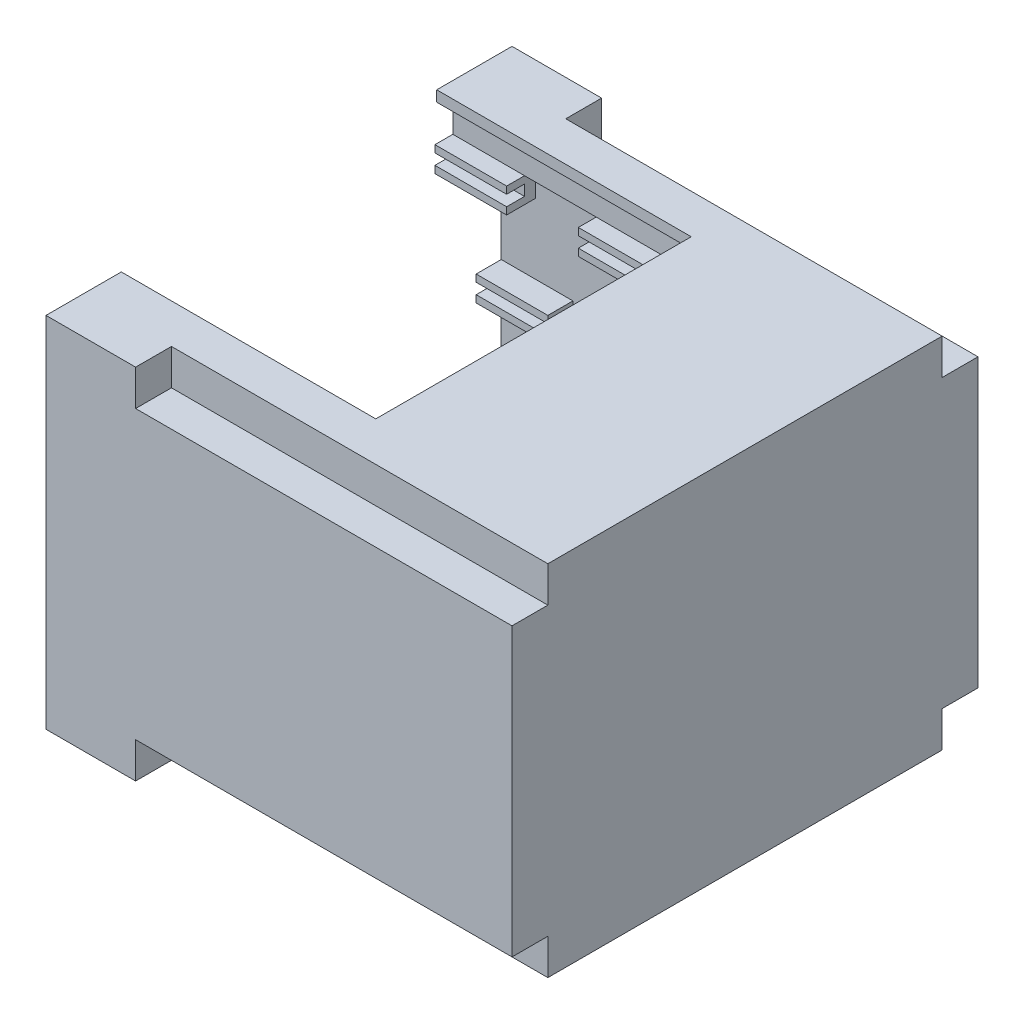
from build123d import *

# Parameters (mm, degrees)
SKETCH2_W                = 130
SKETCH2_H                = 130
BOSS_EXTRUDE1_DEPTH      = 100
SKETCH3_W                = 104
SKETCH3_H                = 74
CUT_EXTRUDE1_DEPTH       = 127
SKETCH4_W                = 10
SKETCH4_H                = 10
CUT_EXTRUDE3_DEPTH       = 105
SKETCH5_W                = 104
SKETCH5_H                = 10
CUT_EXTRUDE4_DEPTH       = 127
SKETCH6_W                = 10
SKETCH6_H                = 74
CUT_EXTRUDE5_DEPTH       = 127
SKETCH7_R                = 1.75
CUT_EXTRUDE6_DEPTH       = 20
SKETCH8_W                = 3
SKETCH8_H                = 3
CUT_EXTRUDE7_DEPTH       = 5
SKETCH9_W                = 85
SKETCH9_H                = 60
BOSS_EXTRUDE2_DEPTH      = 15
SKETCH11_W               = 85
SKETCH11_H               = 6
BOSS_EXTRUDE5_DEPTH      = 5
SKETCH12_W               = 85
SKETCH12_H               = 3
CUT_EXTRUDE9_DEPTH       = 4
SKETCH13_W               = 82
SKETCH13_H               = 57
CUT_EXTRUDE10_DEPTH      = 15
SKETCH15_W               = 3
SKETCH15_H               = 3
BOSS_EXTRUDE7_DEPTH      = 5
SKETCH16_W               = 82
SKETCH16_H               = 2
BOSS_EXTRUDE8_DEPTH      = 57
SKETCH17_W               = 77
SKETCH17_H               = 47
CUT_EXTRUDE11_DEPTH      = 10
SKETCH19_W               = 7
SKETCH19_H               = 2
SKETCH19_H_2             = 1
BOSS_EXTRUDE9_DEPTH      = 1
SKETCH21_W               = 3
SKETCH21_H               = 3
CUT_EXTRUDE15_DEPTH      = 5
SKETCH22_W               = 124
SKETCH22_H               = 7
BOSS_EXTRUDE10_DEPTH     = 127
SKETCH23_W               = 120
SKETCH23_H               = 3
CUT_EXTRUDE16_DEPTH      = 125
SKETCH24_W               = 120
SKETCH24_H               = 110
CUT_EXTRUDE17_DEPTH      = 15
SKETCH25_W               = 71
SKETCH25_H               = 88
CUT_EXTRUDE18_DEPTH      = 15
SKETCH27_W               = 103
SKETCH27_H               = 17
BOSS_EXTRUDE11_DEPTH     = 127
SKETCH28_W               = 97
SKETCH28_H               = 3
SKETCH28_H_2             = 10
CUT_EXTRUDE19_DEPTH      = 120
SKETCH29_W               = 4
SKETCH29_H               = 103
CUT_EXTRUDE20_DEPTH      = 17
SKETCH30_W               = 115
SKETCH30_H               = 87
CUT_EXTRUDE21_DEPTH      = 17
SKETCH31_W               = 20
SKETCH31_H               = 124
CUT_EXTRUDE22_DEPTH      = 37
CUT_EXTRUDE22_DEPTH_BACK = 36
SKETCH32_R               = 3
CUT_EXTRUDE23_DEPTH      = 36
SKETCH34_W               = 0.314102565
SKETCH34_H               = 3.5
CUT_EXTRUDE24_DEPTH      = 0.5


with BuildPart() as part:
    # Sketch2 → Boss-Extrude1 (new body)
    with BuildSketch(Plane(origin=(0, 0, 0), x_dir=(1, 0, 0), z_dir=(0, 1, 0))):
        with Locations((65, 65)):
            Rectangle(SKETCH2_W, SKETCH2_H)
    extrude(amount=BOSS_EXTRUDE1_DEPTH)

    # Sketch3 → Cut-Extrude1 (cut)
    with BuildSketch(Plane.ZY):
        with Locations((-65, 50)):
            Rectangle(SKETCH3_W, SKETCH3_H)
    extrude(amount=-CUT_EXTRUDE1_DEPTH, mode=Mode.SUBTRACT)

    # Sketch4 → Cut-Extrude3 (cut)
    with BuildSketch(Plane(origin=(130, 0, 0), x_dir=(0, 0, -1), z_dir=(1, 0, 0))):
        with Locations((5, 95)):
            Rectangle(SKETCH4_W, SKETCH4_H)
        with Locations((125, 95)):
            Rectangle(SKETCH4_W, SKETCH4_H)
        with Locations((5, 5)):
            Rectangle(SKETCH4_W, SKETCH4_H)
        with Locations((125, 5)):
            Rectangle(SKETCH4_W, SKETCH4_H)
    extrude(amount=-CUT_EXTRUDE3_DEPTH, mode=Mode.SUBTRACT)

    # Sketch5 → Cut-Extrude4 (cut)
    with BuildSketch(Plane.ZY):
        with Locations((-65, 92)):
            Rectangle(SKETCH5_W, SKETCH5_H)
        with Locations((-65, 8)):
            Rectangle(SKETCH5_W, SKETCH5_H)
    extrude(amount=-CUT_EXTRUDE4_DEPTH, mode=Mode.SUBTRACT)

    # Sketch6 → Cut-Extrude5 (cut)
    with BuildSketch(Plane.ZY):
        with Locations((-122, 50)):
            Rectangle(SKETCH6_W, SKETCH6_H)
        with Locations((-8, 50)):
            Rectangle(SKETCH6_W, SKETCH6_H)
    extrude(amount=-CUT_EXTRUDE5_DEPTH, mode=Mode.SUBTRACT)

    # Sketch7 → Cut-Extrude6 (cut)
    with BuildSketch(Plane.ZY):
        with Locations((-124, 94)):
            Circle(SKETCH7_R)
        with Locations((-6, 94)):
            Circle(SKETCH7_R)
        with Locations((-124, 6)):
            Circle(SKETCH7_R)
        with Locations((-6, 6)):
            Circle(SKETCH7_R)
    extrude(amount=-CUT_EXTRUDE6_DEPTH, mode=Mode.SUBTRACT)

    # Sketch8 → Cut-Extrude7 (cut)
    with BuildSketch(Plane.ZY):
        with Locations((-118.5, 88.5)):
            Rectangle(SKETCH8_W, SKETCH8_H)
        with Locations((-11.5, 88.5)):
            Rectangle(SKETCH8_W, SKETCH8_H)
        with Locations((-118.5, 11.5)):
            Rectangle(SKETCH8_W, SKETCH8_H)
        with Locations((-11.5, 11.5)):
            Rectangle(SKETCH8_W, SKETCH8_H)
    extrude(amount=-CUT_EXTRUDE7_DEPTH, mode=Mode.SUBTRACT)

    # Sketch9 → Boss-Extrude2 (add)
    with BuildSketch(Plane(origin=(0, 3, 0), x_dir=(1, 0, 0), z_dir=(0, 1, 0))):
        with Locations((42.5, 87)):
            Rectangle(SKETCH9_W, SKETCH9_H)
    extrude(amount=BOSS_EXTRUDE2_DEPTH)

    # Sketch11 → Boss-Extrude5 (add)
    with BuildSketch(Plane(origin=(0, 13, 0), x_dir=(1, 0, 0), z_dir=(0, 1, 0))):
        with Locations((42.5, 120)):
            Rectangle(SKETCH11_W, SKETCH11_H)
    extrude(amount=BOSS_EXTRUDE5_DEPTH)

    # Sketch12 → Cut-Extrude9 (cut)
    with BuildSketch(Plane(origin=(0, 18, 0), x_dir=(1, 0, 0), z_dir=(0, 1, 0))):
        with Locations((42.5, 121.5)):
            Rectangle(SKETCH12_W, SKETCH12_H)
    extrude(amount=-CUT_EXTRUDE9_DEPTH, mode=Mode.SUBTRACT)

    # Sketch13 → Cut-Extrude10 (cut)
    with BuildSketch(Plane(origin=(0, 18, 0), x_dir=(1, 0, 0), z_dir=(0, 1, 0))):
        with Locations((41, 88.5)):
            Rectangle(SKETCH13_W, SKETCH13_H)
    extrude(amount=-CUT_EXTRUDE10_DEPTH, mode=Mode.SUBTRACT)

    # Sketch15 → Boss-Extrude7 (add)
    with BuildSketch(Plane.ZY.offset(-5)):
        with Locations((-118.5, 11.5)):
            Rectangle(SKETCH15_W, SKETCH15_H)
    extrude(amount=BOSS_EXTRUDE7_DEPTH)

    # Sketch16 → Boss-Extrude8 (add)
    with BuildSketch(Plane(origin=(0, 0, -60), x_dir=(-1, 0, 0), z_dir=(0, 0, -1))):
        with Locations((-41, 17)):
            Rectangle(SKETCH16_W, SKETCH16_H)
        with Locations((-41, 12)):
            Rectangle(SKETCH16_W, SKETCH16_H)
    extrude(amount=BOSS_EXTRUDE8_DEPTH)

    # Sketch17 → Cut-Extrude11 (cut)
    with BuildSketch(Plane(origin=(0, 18, 0), x_dir=(1, 0, 0), z_dir=(0, 1, 0))):
        with Locations((38.5, 88.5)):
            Rectangle(SKETCH17_W, SKETCH17_H)
    extrude(amount=-CUT_EXTRUDE11_DEPTH, mode=Mode.SUBTRACT)

    # Sketch19 → Boss-Extrude9 (add)
    with BuildSketch(Plane.XY.offset(-117)):
        with Locations((3.5, 10)):
            Rectangle(SKETCH19_W, SKETCH19_H)
        with Locations((3.5, 13.5)):
            Rectangle(SKETCH19_W, SKETCH19_H_2)
    extrude(amount=BOSS_EXTRUDE9_DEPTH)

    # Sketch21 → Cut-Extrude15 (cut)
    with BuildSketch(Plane.ZY):
        with Locations((-118.5, 11.5)):
            Rectangle(SKETCH21_W, SKETCH21_H)
    extrude(amount=-CUT_EXTRUDE15_DEPTH, mode=Mode.SUBTRACT)

    # Sketch22 → Boss-Extrude10 (add)
    with BuildSketch(Plane.ZY.offset(-127)):
        with Locations((-65, 46.5)):
            Rectangle(SKETCH22_W, SKETCH22_H)
    extrude(amount=BOSS_EXTRUDE10_DEPTH)

    # Sketch23 → Cut-Extrude16 (cut)
    with BuildSketch(Plane.ZY):
        with Locations((-65, 46.5)):
            Rectangle(SKETCH23_W, SKETCH23_H)
    extrude(amount=-CUT_EXTRUDE16_DEPTH, mode=Mode.SUBTRACT)

    # Sketch24 → Cut-Extrude17 (cut)
    with BuildSketch(Plane(origin=(0, 50, 0), x_dir=(1, 0, 0), z_dir=(0, 1, 0))):
        with Locations((60, 65)):
            Rectangle(SKETCH24_W, SKETCH24_H)
    extrude(amount=-CUT_EXTRUDE17_DEPTH, mode=Mode.SUBTRACT)

    # Sketch25 → Cut-Extrude18 (cut)
    with BuildSketch(Plane(origin=(0, 100, 0), x_dir=(1, 0, 0), z_dir=(0, 1, 0))):
        with Locations((35.5, 65)):
            Rectangle(SKETCH25_W, SKETCH25_H)
    extrude(amount=-CUT_EXTRUDE18_DEPTH, mode=Mode.SUBTRACT)

    # Sketch27 → Boss-Extrude11 (add)
    with BuildSketch(Plane.ZY.offset(-127)):
        with Locations((-65, 88.5)):
            Rectangle(SKETCH27_W, SKETCH27_H)
    extrude(amount=BOSS_EXTRUDE11_DEPTH)

    # Sketch28 → Cut-Extrude19 (cut)
    with BuildSketch(Plane.ZY):
        with Locations((-65, 83.5)):
            Rectangle(SKETCH28_W, SKETCH28_H)
        with Locations((-65, 92)):
            Rectangle(SKETCH28_W, SKETCH28_H_2)
    extrude(amount=-CUT_EXTRUDE19_DEPTH, mode=Mode.SUBTRACT)

    # Sketch29 → Cut-Extrude20 (cut)
    with BuildSketch(Plane.XZ.offset(-80)):
        with Locations((125, -65)):
            Rectangle(SKETCH29_W, SKETCH29_H)
    extrude(amount=-CUT_EXTRUDE20_DEPTH, mode=Mode.SUBTRACT)

    # Sketch30 → Cut-Extrude21 (cut)
    with BuildSketch(Plane(origin=(0, 87, 0), x_dir=(1, 0, 0), z_dir=(0, 1, 0))):
        with Locations((57.5, 65)):
            Rectangle(SKETCH30_W, SKETCH30_H)
    extrude(amount=-CUT_EXTRUDE21_DEPTH, mode=Mode.SUBTRACT)

    # Sketch31 → Cut-Extrude22 (cut, two sides)
    with BuildSketch(Plane(origin=(0, 50, 0), x_dir=(1, 0, 0), z_dir=(0, 1, 0))) as cut_extrude22_sk:
        with Locations((30, 65)):
            Rectangle(SKETCH31_W, SKETCH31_H)
    extrude(amount=CUT_EXTRUDE22_DEPTH, mode=Mode.SUBTRACT)
    extrude(cut_extrude22_sk.sketch, amount=-CUT_EXTRUDE22_DEPTH_BACK, mode=Mode.SUBTRACT)

    # Sketch32 → Cut-Extrude23 (cut)
    with BuildSketch(Plane.XY.offset(-127)):
        with Locations((94, 25)):
            Circle(SKETCH32_R)
        with Locations((110, 25)):
            Circle(SKETCH32_R)
    extrude(amount=-CUT_EXTRUDE23_DEPTH, mode=Mode.SUBTRACT)

    # Sketch34 → Cut-Extrude24 (cut)
    with BuildSketch(Plane(origin=(0, 0, -130), x_dir=(-1, 0, 0), z_dir=(0, 0, -1))):
        with BuildLine():
            add(Edge.make_bspline(
                [(-112.535670544, 19.604023369), (-112.470862438, 19.602381889), (-112.343573971, 19.599157888), (-112.156499073, 19.574478785), (-111.977903978, 19.531783395), (-111.806333839, 19.474920412), (-111.643840863, 19.399066027), (-111.48920197, 19.307380879), (-111.342785096, 19.19890442), (-111.206563715, 19.074475193), (-111.081906765, 18.939091739), (-110.972080878, 18.794613829), (-110.880038585, 18.641915027), (-110.804452797, 18.481454196), (-110.745154188, 18.313594228), (-110.704235144, 18.137440225), (-110.678096994, 17.954133535), (-110.675041216, 17.829106671), (-110.673491057, 17.765682022)],
                knots=[0, 0, 0, 0, 0.000194393, 0.000381804, 0.00056479, 0.000744601, 0.000923091, 0.001101652, 0.001283106, 0.001468738, 0.001654324, 0.001834514, 0.002012231, 0.002188181, 0.002365797, 0.002545211, 0.002729936, 0.002920126, 0.002920126, 0.002920126, 0.002920126], degree=3))
            add(Edge.make_bspline(
                [(-110.673491057, 17.765682022), (-110.675040989, 17.702724576), (-110.678096086, 17.578628156), (-110.704264863, 17.396484711), (-110.745305863, 17.221394015), (-110.80390213, 17.053648362), (-110.879127608, 16.893070798), (-110.971782779, 16.740083845), (-111.08092399, 16.594637346), (-111.205130841, 16.458324681), (-111.340531883, 16.33332721), (-111.48576215, 16.224408335), (-111.63755547, 16.13068421), (-111.797865178, 16.055900536), (-111.964565215, 15.996128616), (-112.139147538, 15.955375986), (-112.320794092, 15.929088942), (-112.444665096, 15.926070426), (-112.507625672, 15.924536189)],
                knots=[0, 0, 0, 0, 0.000188789, 0.000372126, 0.000550857, 0.00072758, 0.000904164, 0.001081881, 0.001263191, 0.001448823, 0.00163441, 0.001815159, 0.001992641, 0.002168591, 0.002344885, 0.002522934, 0.002705576, 0.002894365, 0.002894365, 0.002894365, 0.002894365], degree=3))
            add(Edge.make_bspline(
                [(-112.507625672, 15.924536189), (-112.571049991, 15.926085576), (-112.696076207, 15.92913983), (-112.879613242, 15.955321235), (-113.055890986, 15.996262539), (-113.224405338, 16.054771975), (-113.385250267, 16.130389205), (-113.53874035, 16.222593585), (-113.684259497, 16.332000726), (-113.820601244, 16.4561673), (-113.945350442, 16.591338852), (-114.054109817, 16.736173107), (-114.146334931, 16.887828564), (-114.221698263, 17.046726088), (-114.281362723, 17.212097531), (-114.322067541, 17.385046008), (-114.348403493, 17.564585514), (-114.351438339, 17.686828412), (-114.352978236, 17.748855099)],
                knots=[0, 0, 0, 0, 0.00019019, 0.000374915, 0.000555011, 0.000732396, 0.00090898, 0.001087298, 0.001268608, 0.00145424, 0.001639827, 0.001819595, 0.001996712, 0.002171394, 0.002346367, 0.002523053, 0.002703612, 0.002889599, 0.002889599, 0.002889599, 0.002889599], degree=3))
            add(Edge.make_bspline(
                [(-114.352978236, 17.748855099), (-114.352443601, 17.790487769), (-114.351381074, 17.873227892), (-114.338589382, 17.996094492), (-114.320027681, 18.11698515), (-114.293425768, 18.235556098), (-114.258634101, 18.351517083), (-114.217582074, 18.465667845), (-114.167442228, 18.576851569), (-114.11076158, 18.685594961), (-114.047499772, 18.790202867), (-113.977624023, 18.88908245), (-113.903588654, 18.983063447), (-113.822425261, 19.069710451), (-113.736808816, 19.151544107), (-113.645350438, 19.227306824), (-113.548608193, 19.297681775), (-113.446165813, 19.361102116), (-113.340547539, 19.418461251), (-113.231670761, 19.467683102), (-113.121014189, 19.509929163), (-113.008059541, 19.544169988), (-112.893106769, 19.571202024), (-112.775904985, 19.589609378), (-112.656547558, 19.602433696), (-112.576136239, 19.603491198), (-112.535670544, 19.604023369)],
                knots=[0, 0, 0, 0, 0.000124849, 0.000248123, 0.000370193, 0.00049164, 0.000612319, 0.000733199, 0.000855287, 0.000977905, 0.001100913, 0.001221706, 0.001340948, 0.001459521, 0.001577551, 0.001696047, 0.001815534, 0.001936153, 0.002057243, 0.002175846, 0.002294342, 0.002412335, 0.002529682, 0.00264829, 0.002768075, 0.00288942, 0.00288942, 0.00288942, 0.00288942], degree=3))
        make_face()
        with BuildLine():
            add(Edge.make_bspline(
                [(-112.520245864, 19.24504901), (-112.553460498, 19.244644119), (-112.619572231, 19.24383821), (-112.717856767, 19.233222494), (-112.814848701, 19.218092605), (-112.910568063, 19.196511084), (-113.004614353, 19.167107032), (-113.097864194, 19.133266123), (-113.189467248, 19.092045033), (-113.279121105, 19.045472328), (-113.366036181, 18.993923408), (-113.448048882, 18.936951641), (-113.525371526, 18.875893086), (-113.597814793, 18.810605249), (-113.665165965, 18.740755647), (-113.728750666, 18.667403211), (-113.786020248, 18.58845132), (-113.838505825, 18.506040913), (-113.885473665, 18.420279332), (-113.92723902, 18.33206947), (-113.961403029, 18.240691783), (-113.989265405, 18.147137625), (-114.012365216, 18.051555166), (-114.02699914, 17.953219317), (-114.037731499, 17.852624205), (-114.038491345, 17.784642351), (-114.038875672, 17.750257343)],
                knots=[0, 0, 0, 0, 9.9599e-05, 0.000198245, 0.000296222, 0.00039402, 0.00049227, 0.000591646, 0.000691452, 0.000793368, 0.000894612, 0.000994383, 0.001092713, 0.00119001, 0.001286696, 0.001383657, 0.001480979, 0.001579008, 0.001676595, 0.001774142, 0.001871547, 0.001968922, 0.002066879, 0.00216624, 0.00226698, 0.002370083, 0.002370083, 0.002370083, 0.002370083], degree=3))
            add(Edge.make_bspline(
                [(-114.038875672, 17.750257343), (-114.03760081, 17.699695122), (-114.035092762, 17.600223592), (-114.013135192, 17.454455448), (-113.979313218, 17.314367162), (-113.929455851, 17.180725252), (-113.867105237, 17.05238097), (-113.790078346, 16.930472865), (-113.698819261, 16.814967991), (-113.595155734, 16.706672722), (-113.481833028, 16.607826917), (-113.361500298, 16.521063509), (-113.23544669, 16.447653259), (-113.103343488, 16.387848186), (-112.965895948, 16.340458449), (-112.822218397, 16.307979818), (-112.673267938, 16.286604362), (-112.571737283, 16.284551606), (-112.520245864, 16.283510548)],
                knots=[0, 0, 0, 0, 0.000151605, 0.000298253, 0.000441263, 0.000583229, 0.000725274, 0.000868635, 0.001014928, 0.001166177, 0.001317744, 0.00146543, 0.001610576, 0.001754594, 0.001899821, 0.002045914, 0.002195936, 0.002350312, 0.002350312, 0.002350312, 0.002350312], degree=3))
            add(Edge.make_bspline(
                [(-112.520245864, 16.283510548), (-112.485636363, 16.283986052), (-112.416995326, 16.28492912), (-112.314899804, 16.294427797), (-112.214643592, 16.309659667), (-112.116367313, 16.331590322), (-112.020182501, 16.359037529), (-111.925687698, 16.391645257), (-111.833889408, 16.43232646), (-111.74362957, 16.477274412), (-111.657233328, 16.528514569), (-111.574757796, 16.583552719), (-111.498281816, 16.64452134), (-111.425892745, 16.708839152), (-111.358265056, 16.777803), (-111.295856071, 16.851323222), (-111.238875939, 16.929863879), (-111.186410293, 17.012149285), (-111.13960703, 17.098145538), (-111.098827931, 17.186675216), (-111.064231815, 17.277520325), (-111.03630331, 17.370811897), (-111.014417849, 17.466372745), (-110.999337929, 17.564330823), (-110.98878949, 17.664490166), (-110.987994413, 17.732234022), (-110.987593621, 17.766383144)],
                knots=[0, 0, 0, 0, 0.000103804, 0.000205874, 0.000307314, 0.000407849, 0.000507719, 0.000607281, 0.000707445, 0.000808723, 0.000909609, 0.001008589, 0.001105934, 0.001202762, 0.001298946, 0.001395452, 0.001491794, 0.001589823, 0.001688026, 0.001785277, 0.001882027, 0.001979402, 0.0020772, 0.002175869, 0.002276609, 0.002379011, 0.002379011, 0.002379011, 0.002379011], degree=3))
            add(Edge.make_bspline(
                [(-110.987593621, 17.766383144), (-110.987994734, 17.800298649), (-110.988790415, 17.867576299), (-110.99933289, 17.967037117), (-111.01443378, 18.064290329), (-111.036196488, 18.158954132), (-111.064246642, 18.251052657), (-111.098833973, 18.340499404), (-111.139619272, 18.427627599), (-111.186427496, 18.512221896), (-111.23904332, 18.593396634), (-111.296537563, 18.670999047), (-111.359902911, 18.743571788), (-111.427328936, 18.812906482), (-111.500499821, 18.877524372), (-111.579084116, 18.937446893), (-111.662127793, 18.994120167), (-111.750055029, 19.045245729), (-111.840798983, 19.092459961), (-111.93391294, 19.132910964), (-112.02834204, 19.167283084), (-112.123846152, 19.196600049), (-112.221229131, 19.218008079), (-112.31983296, 19.233236129), (-112.419521218, 19.243834515), (-112.486564438, 19.244642893), (-112.520245864, 19.24504901)],
                knots=[0, 0, 0, 0, 0.000101701, 0.000201743, 0.00029972, 0.000396835, 0.000492868, 0.000588308, 0.000684288, 0.000781261, 0.000878109, 0.000974304, 0.001070733, 0.001166917, 0.001264269, 0.001363274, 0.001463228, 0.001565678, 0.001668217, 0.001769947, 0.001869982, 0.001969573, 0.002069423, 0.002168785, 0.002268827, 0.002369827, 0.002369827, 0.002369827, 0.002369827], degree=3))
        make_face(mode=Mode.SUBTRACT)
        with BuildLine():
            Line((-109.955542339, 19.514279779), (-109.641439775, 19.514279779))
            Line((-109.641439775, 19.514279779), (-109.641439775, 17.41722449))
            add(Edge.make_bspline(
                [(-109.641439775, 17.41722449), (-109.641486519, 17.387543755), (-109.641575223, 17.331219444), (-109.64098271, 17.251051143), (-109.639323341, 17.179778684), (-109.638277182, 17.117127337), (-109.635949848, 17.063384589), (-109.634051801, 17.018259278), (-109.631611244, 16.981965076), (-109.628678127, 16.96078415), (-109.627417339, 16.951679619)],
                knots=[0, 0, 0, 0, 8.9042e-05, 0.000168973, 0.000240502, 0.000302917, 0.000356945, 0.000401866, 0.000438432, 0.000465999, 0.000465999, 0.000465999, 0.000465999], degree=3))
            add(Edge.make_bspline(
                [(-109.627417339, 16.951679619), (-109.62223988, 16.918832855), (-109.612176694, 16.854990126), (-109.586530316, 16.764081844), (-109.550712815, 16.682150386), (-109.508269772, 16.606639095), (-109.452337161, 16.539649735), (-109.385333626, 16.477938082), (-109.304155857, 16.423966277), (-109.213895251, 16.374615466), (-109.116610014, 16.334950383), (-109.017198748, 16.304957019), (-108.917155768, 16.286678119), (-108.850179603, 16.28456158), (-108.816920544, 16.283510548)],
                knots=[0, 0, 0, 0, 9.971e-05, 0.000193801, 0.000282365, 0.000367504, 0.000452699, 0.000543015, 0.000639862, 0.000744331, 0.000851226, 0.000954377, 0.001055468, 0.001155185, 0.001155185, 0.001155185, 0.001155185], degree=3))
            add(Edge.make_bspline(
                [(-108.816920544, 16.283510548), (-108.788366804, 16.284584398), (-108.731424242, 16.286725897), (-108.646817811, 16.299987328), (-108.564417702, 16.323887893), (-108.483817022, 16.354727652), (-108.408266038, 16.395475243), (-108.337722596, 16.442546082), (-108.274758662, 16.497756958), (-108.217300664, 16.558857303), (-108.167265728, 16.627797103), (-108.123894586, 16.703075241), (-108.088368657, 16.785824588), (-108.070825132, 16.84397901), (-108.061812371, 16.873855099)],
                knots=[0, 0, 0, 0, 8.5678e-05, 0.00017086, 0.000256092, 0.000342674, 0.000429242, 0.000513055, 0.000596556, 0.000679898, 0.000764179, 0.00085149, 0.000940054, 0.001033621, 0.001033621, 0.001033621, 0.001033621], degree=3))
            add(Edge.make_bspline(
                [(-108.061812371, 16.873855099), (-108.058812246, 16.886203674), (-108.052126757, 16.913721274), (-108.045879712, 16.960242564), (-108.039373187, 17.015131928), (-108.034858617, 17.078783741), (-108.030457397, 17.150984714), (-108.027824324, 17.232110971), (-108.026607291, 17.321867932), (-108.026244611, 17.384505094), (-108.026055159, 17.41722449)],
                knots=[0, 0, 0, 0, 3.81e-05, 8.4902e-05, 0.000140649, 0.000203941, 0.000276279, 0.000357657, 0.000447412, 0.000545571, 0.000545571, 0.000545571, 0.000545571], degree=3))
            Line((-108.026055159, 17.41722449), (-108.026055159, 19.514279779))
            Line((-108.026055159, 19.514279779), (-107.711952595, 19.514279779))
            Line((-107.711952595, 19.514279779), (-107.711952595, 17.400397567))
            add(Edge.make_bspline(
                [(-107.711952595, 17.400397567), (-107.712206716, 17.362299188), (-107.712702647, 17.287947885), (-107.717003224, 17.178996526), (-107.723860223, 17.075643545), (-107.733548311, 16.977875049), (-107.746385315, 16.886040889), (-107.760660535, 16.799336121), (-107.778840068, 16.718383129), (-107.800073469, 16.642550711), (-107.824347017, 16.570365197), (-107.855788166, 16.501856583), (-107.891212666, 16.434942183), (-107.933227318, 16.370634074), (-107.980438701, 16.308647521), (-108.033890382, 16.249358446), (-108.091814543, 16.1918194), (-108.155174102, 16.137506334), (-108.222924628, 16.087697657), (-108.294864585, 16.043899886), (-108.370441355, 16.006876268), (-108.449458481, 15.976400344), (-108.531949684, 15.953485745), (-108.617917044, 15.936410589), (-108.707556237, 15.926708291), (-108.768520893, 15.925266361), (-108.799392499, 15.924536189)],
                knots=[0, 0, 0, 0, 0.000114291, 0.000223047, 0.000327049, 0.000424998, 0.000517708, 0.000605194, 0.000688542, 0.000766455, 0.0008414, 0.000916717, 0.000992315, 0.001068354, 0.001146882, 0.001225836, 0.001307639, 0.001391671, 0.001475952, 0.001559641, 0.001643989, 0.001728103, 0.001813335, 0.001900511, 0.00199079, 0.002083404, 0.002083404, 0.002083404, 0.002083404], degree=3))
            add(Edge.make_bspline(
                [(-108.799392499, 15.924536189), (-108.833061602, 15.925320954), (-108.899120261, 15.926860661), (-108.996458328, 15.935683411), (-109.089772524, 15.952301805), (-109.180048401, 15.973461749), (-109.266056898, 16.002645486), (-109.348950343, 16.036743611), (-109.427309024, 16.078620872), (-109.502404152, 16.125214265), (-109.572228909, 16.177638903), (-109.636326312, 16.234779077), (-109.694802182, 16.295719454), (-109.746670879, 16.36111982), (-109.792791763, 16.430471527), (-109.832521977, 16.503970767), (-109.866635221, 16.581589083), (-109.884241788, 16.635542283), (-109.893142499, 16.662817439)],
                knots=[0, 0, 0, 0, 0.000101022, 0.000198206, 0.000292839, 0.000385177, 0.00047608, 0.000565014, 0.000653769, 0.000742283, 0.000829923, 0.000915339, 0.000999643, 0.001082971, 0.00116542, 0.001249186, 0.001333332, 0.001419362, 0.001419362, 0.001419362, 0.001419362], degree=3))
            add(Edge.make_bspline(
                [(-109.893142499, 16.662817439), (-109.898319657, 16.681450014), (-109.909549029, 16.721864483), (-109.921574326, 16.788750971), (-109.931683408, 16.865765889), (-109.941188966, 16.952914507), (-109.946797924, 17.050264374), (-109.951715363, 17.15777329), (-109.955576982, 17.275571251), (-109.955554209, 17.357625767), (-109.955542339, 17.400397567)],
                knots=[0, 0, 0, 0, 5.799e-05, 0.000125782, 0.000203619, 0.000291034, 0.000388694, 0.000496078, 0.000613919, 0.000742226, 0.000742226, 0.000742226, 0.000742226], degree=3))
            Line((-109.955542339, 17.400397567), (-109.955542339, 19.514279779))
        make_face()
        Polygon((-107.218362852, 19.15530542), (-107.218362852, 19.514279779), (-105.378619262, 19.514279779), (-105.378619262, 19.15530542), (-106.141439775, 19.15530542), (-106.141439775, 16.014279779), (-106.455542339, 16.014279779), (-106.455542339, 19.15530542), align=None)
        with Locations((-95.798913964, 17.427183126)):
            Rectangle(SKETCH34_W, SKETCH34_H)
        Polygon((-94.744426784, 15.677183126), (-94.744426784, 19.177183126), (-94.678521335, 19.177183126), (-92.366221656, 16.422475594), (-92.366221656, 19.177183126), (-92.052119092, 19.177183126), (-92.052119092, 15.677183126), (-92.123633515, 15.677183126), (-94.43032422, 18.425580562), (-94.43032422, 15.677183126), align=None)
    extrude(amount=-CUT_EXTRUDE24_DEPTH, mode=Mode.SUBTRACT)


solid = part.part
